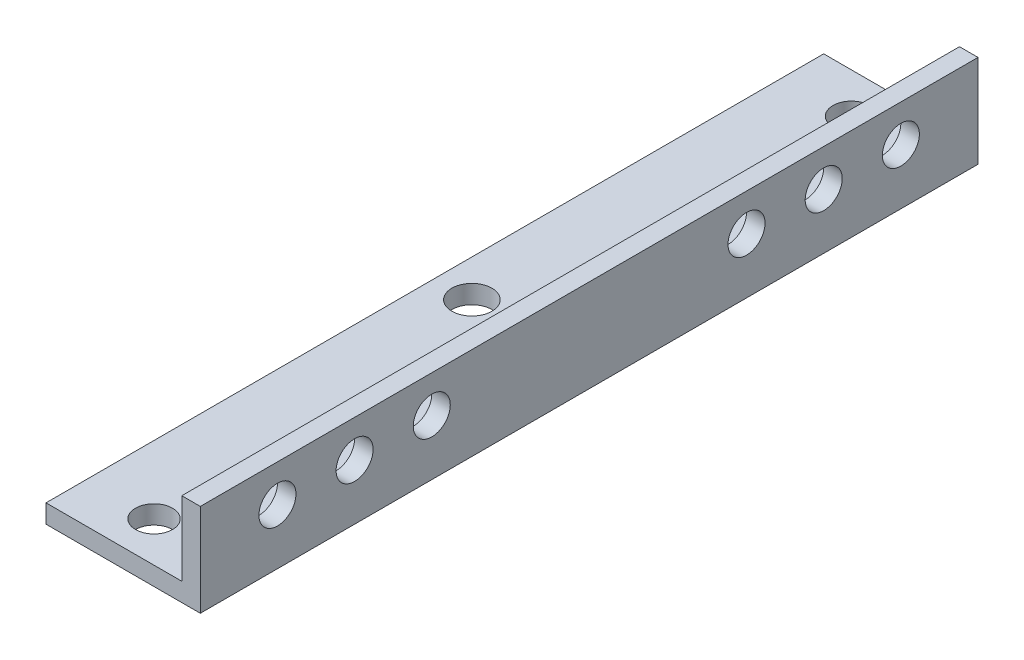
from build123d import *

# Parameters (mm, degrees)
SALIENTE_EXTRUIR1_DEPTH = 126
CROQUIS2_R              = 3
CORTAR_EXTRUIR3_DEPTH   = 63
CROQUIS3_R              = 3
CROQUIS3_R_2            = 3.243437353
CROQUIS3_R_3            = 3.351130608
CORTAR_EXTRUIR4_DEPTH   = 10


with BuildPart() as part:
    # Croquis1 → Saliente-Extruir1 (new body)
    with BuildSketch(Plane.XY):
        Polygon((0, 0), (3, 0), (3, -15), (-22, -15), (-22, -12), (0, -12), align=None)
    extrude(amount=SALIENTE_EXTRUIR1_DEPTH)

    # Croquis2 → Cortar-Extruir3 (cut, symmetric)
    with BuildSketch(Plane(origin=(3, 0, 0), x_dir=(0, 0, -1), z_dir=(1, 0, 0))):
        with Locations((-113.5, -6)):
            Circle(CROQUIS2_R)
        with Locations((-101, -6)):
            Circle(CROQUIS2_R)
        with Locations((-88.5, -6)):
            Circle(CROQUIS2_R)
        with Locations((-12.5, -6)):
            Circle(CROQUIS2_R)
        with Locations((-25, -6)):
            Circle(CROQUIS2_R)
        with Locations((-37.5, -6)):
            Circle(CROQUIS2_R)
    extrude(amount=CORTAR_EXTRUIR3_DEPTH, both=True, mode=Mode.SUBTRACT)

    # Croquis3 → Cortar-Extruir4 (cut)
    with BuildSketch(Plane(origin=(0, -12, 0), x_dir=(1, 0, 0), z_dir=(0, 1, 0))):
        with Locations((-11, -6.5)):
            Circle(CROQUIS3_R)
        with Locations((-11, -119.5)):
            Circle(CROQUIS3_R)
        with Locations((-16, -63)):
            Circle(CROQUIS3_R_2)
        with Locations((-6, -63)):
            Circle(CROQUIS3_R_3)
    extrude(amount=-CORTAR_EXTRUIR4_DEPTH, mode=Mode.SUBTRACT)


solid = part.part
